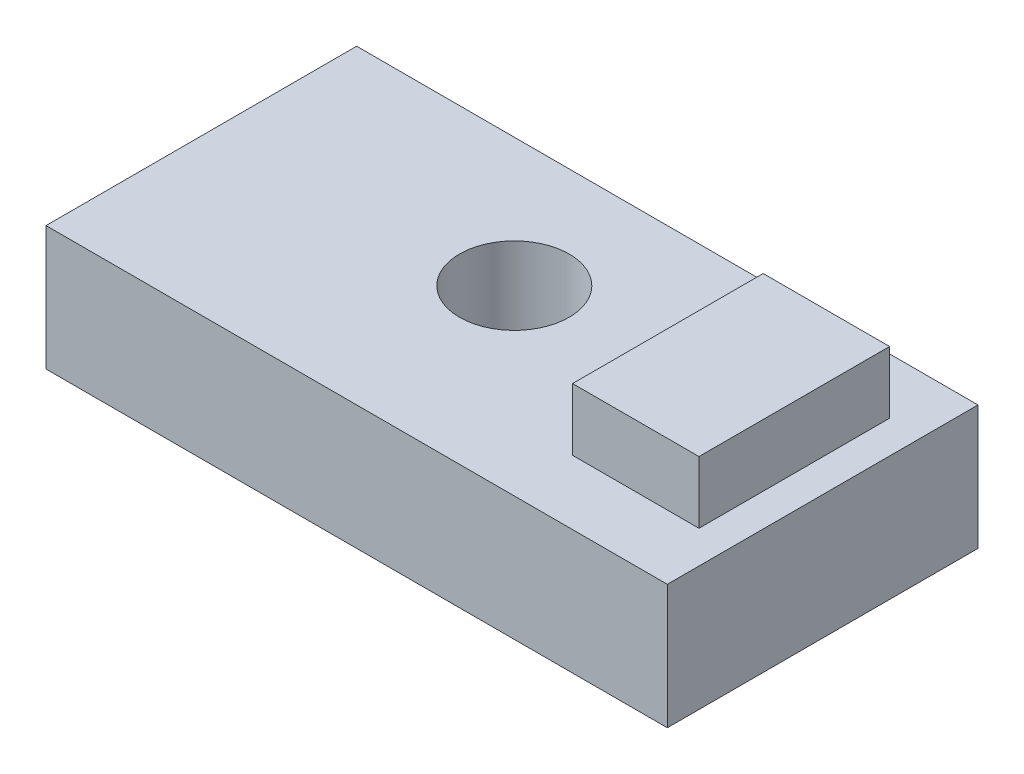
from build123d import *

# Parameters (mm, degrees)
SKETCH1_W           = 3810
SKETCH1_H           = 1905
BOSS_EXTRUDE1_DEPTH = 762
SKETCH2_R           = 336.258211588
CUT_EXTRUDE1_DEPTH  = 763
SKETCH3_W           = 775.150416673
SKETCH3_H           = 1168.813193726
BOSS_EXTRUDE2_DEPTH = 381


with BuildPart() as part:
    # Sketch1 → Boss-Extrude1 (new body)
    with BuildSketch(Plane(origin=(0, 0, 0), x_dir=(1, 0, 0), z_dir=(0, 1, 0))):
        with Locations((1562.626728111, 175.576036866)):
            Rectangle(SKETCH1_W, SKETCH1_H)
    extrude(amount=BOSS_EXTRUDE1_DEPTH)

    # Sketch2 → Cut-Extrude1 (cut, through all)
    with BuildSketch(Plane(origin=(0, 762, 0), x_dir=(1, 0, 0), z_dir=(0, 1, 0))):
        with Locations((1412.4667322, 339.940416015)):
            Circle(SKETCH2_R)
    extrude(amount=-CUT_EXTRUDE1_DEPTH, mode=Mode.SUBTRACT)

    # Sketch3 → Boss-Extrude2 (add)
    with BuildSketch(Plane(origin=(0, 762, 0), x_dir=(1, 0, 0), z_dir=(0, 1, 0))):
        with Locations((2879.570760626, 201.955501308)):
            Rectangle(SKETCH3_W, SKETCH3_H)
    extrude(amount=BOSS_EXTRUDE2_DEPTH)


solid = part.part
